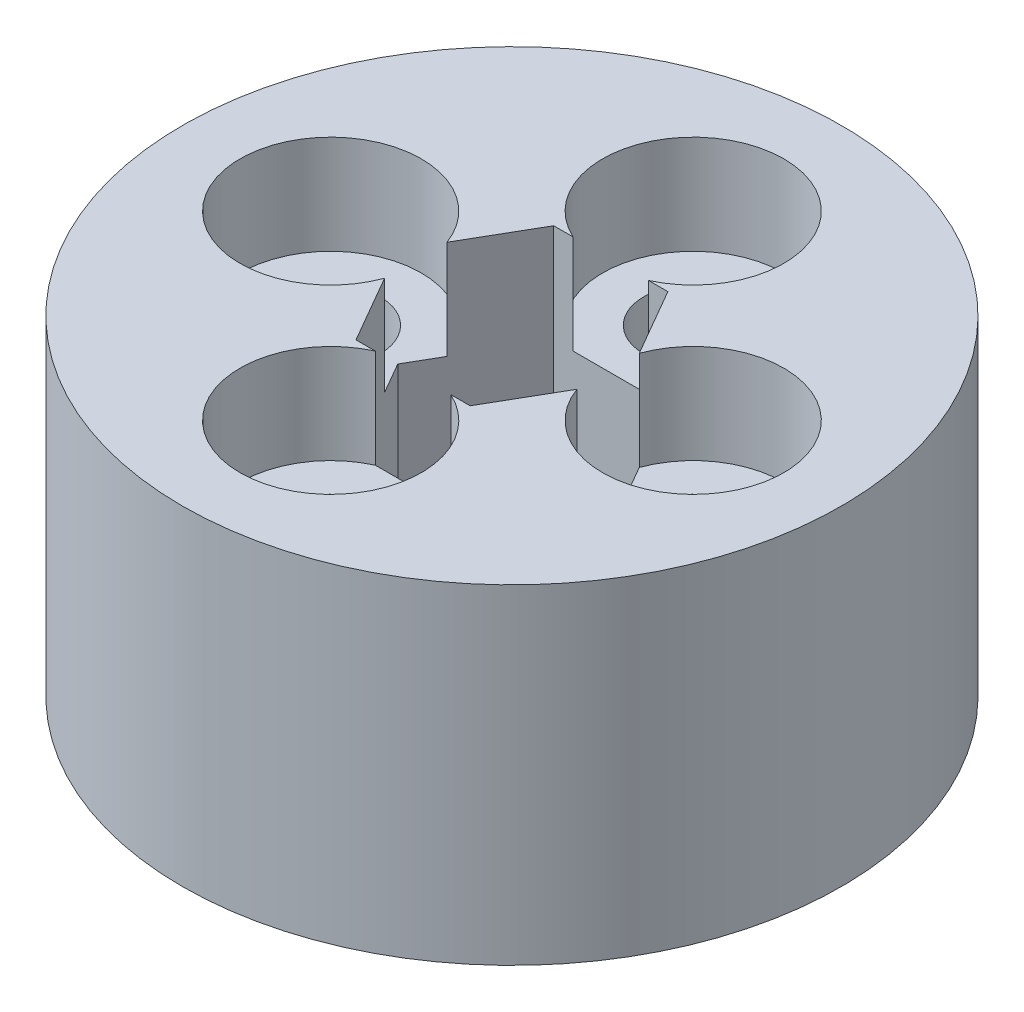
from build123d import *

# Parameters (mm, degrees)
SKETCH1_R           = 10
SKETCH1_R_2         = 1.5
BOSS_EXTRUDE1_DEPTH = 10
SKETCH2_R           = 2.75
CUT_EXTRUDE1_DEPTH  = 3
CUT_EXTRUDE2_DEPTH  = 7


with BuildPart() as part:
    # Sketch1 → Boss-Extrude1 (new body)
    with BuildSketch(Plane(origin=(0, 0, 0), x_dir=(1, 0, 0), z_dir=(0, 1, 0))):
        Circle(SKETCH1_R)
        with Locations((0, 5.5)):
            Circle(SKETCH1_R_2, mode=Mode.SUBTRACT)
        with Locations((5.5, 0)):
            Circle(SKETCH1_R_2, mode=Mode.SUBTRACT)
        with Locations((0, -5.5)):
            Circle(SKETCH1_R_2, mode=Mode.SUBTRACT)
        with Locations((-5.5, 0)):
            Circle(SKETCH1_R_2, mode=Mode.SUBTRACT)
    extrude(amount=BOSS_EXTRUDE1_DEPTH)

    # Sketch2 → Cut-Extrude1 (cut)
    with BuildSketch(Plane(origin=(0, 10, 0), x_dir=(1, 0, 0), z_dir=(0, 1, 0))):
        with Locations((0, 5.5)):
            Circle(SKETCH2_R)
        with Locations((5.5, 0)):
            Circle(SKETCH2_R)
        with Locations((0, -5.5)):
            Circle(SKETCH2_R)
        with Locations((-5.5, 0)):
            Circle(SKETCH2_R)
    extrude(amount=-CUT_EXTRUDE1_DEPTH, mode=Mode.SUBTRACT)

    # Sketch3 → Cut-Extrude2 (cut)
    with BuildSketch(Plane(origin=(0, 10, 0), x_dir=(1, 0, 0), z_dir=(0, 1, 0))):
        Polygon((3.464101615, 0), (1.732050808, 3), (-1.732050808, 3), (-3.464101615, 0), (-1.732050808, -3), (1.732050808, -3), align=None)
    extrude(amount=-CUT_EXTRUDE2_DEPTH, mode=Mode.SUBTRACT)


solid = part.part
